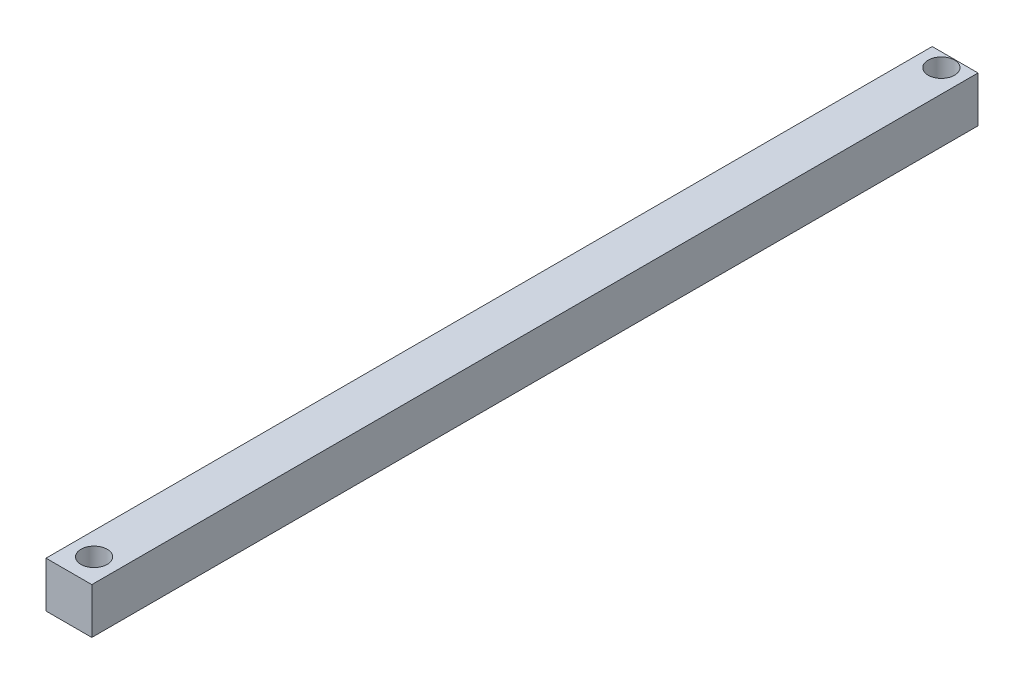
from build123d import *

# Parameters (mm, degrees)
SKETCH1_W           = 20
SKETCH1_H           = 387
BOSS_EXTRUDE1_DEPTH = 20
SKETCH3_R           = 5.75
CUT_EXTRUDE1_DEPTH  = 21


with BuildPart() as part:
    # Sketch1 → Boss-Extrude1 (new body)
    with BuildSketch(Plane(origin=(0, 0, 0), x_dir=(1, 0, 0), z_dir=(0, 1, 0))):
        Rectangle(SKETCH1_W, SKETCH1_H)
    extrude(amount=BOSS_EXTRUDE1_DEPTH)

    # Sketch3 → Cut-Extrude1 (cut, through all)
    with BuildSketch(Plane(origin=(0, 20, 0), x_dir=(1, 0, 0), z_dir=(0, 1, 0))):
        with Locations((0, 187.5)):
            Circle(SKETCH3_R)
        with Locations((0, -182.5)):
            Circle(SKETCH3_R)
    extrude(amount=-CUT_EXTRUDE1_DEPTH, mode=Mode.SUBTRACT)


solid = part.part
